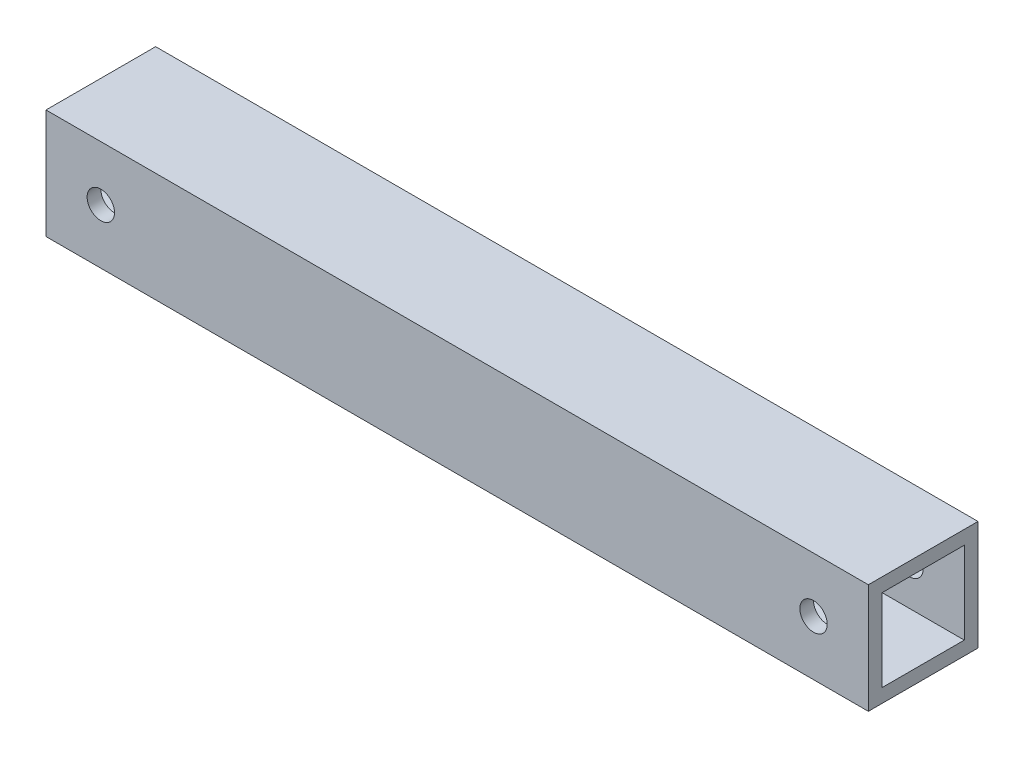
from build123d import *

# Parameters (mm, degrees)
SKETCH1_W           = 190.5
SKETCH1_H           = 25.4
BOSS_EXTRUDE1_DEPTH = 25.4
SKETCH2_W           = 9.525
SKETCH2_H           = 19.040717284
CUT_EXTRUDE1_DEPTH  = 508
SKETCH4_R           = 3.175
CUT_EXTRUDE3_DEPTH  = 508


with BuildPart() as part:
    # Sketch1 → Boss-Extrude1 (new body)
    with BuildSketch(Plane.XY):
        Rectangle(SKETCH1_W, SKETCH1_H)
    extrude(amount=BOSS_EXTRUDE1_DEPTH)

    # Sketch2 → Cut-Extrude1 (cut)
    with BuildSketch(Plane(origin=(95.25, 0, 0), x_dir=(0, 0, -1), z_dir=(1, 0, 0))):
        with Locations((-17.4625, 0)):
            Rectangle(SKETCH2_W, SKETCH2_H)
        with Locations((-7.9375, 0)):
            Rectangle(SKETCH2_W, SKETCH2_H)
    extrude(amount=-CUT_EXTRUDE1_DEPTH, mode=Mode.SUBTRACT)

    # Sketch4 → Cut-Extrude3 (cut)
    with BuildSketch(Plane.XY.offset(25.4)):
        with Locations((-82.55, 0)):
            Circle(SKETCH4_R)
        with Locations((82.55, 0)):
            Circle(SKETCH4_R)
    extrude(amount=-CUT_EXTRUDE3_DEPTH, mode=Mode.SUBTRACT)


solid = part.part
